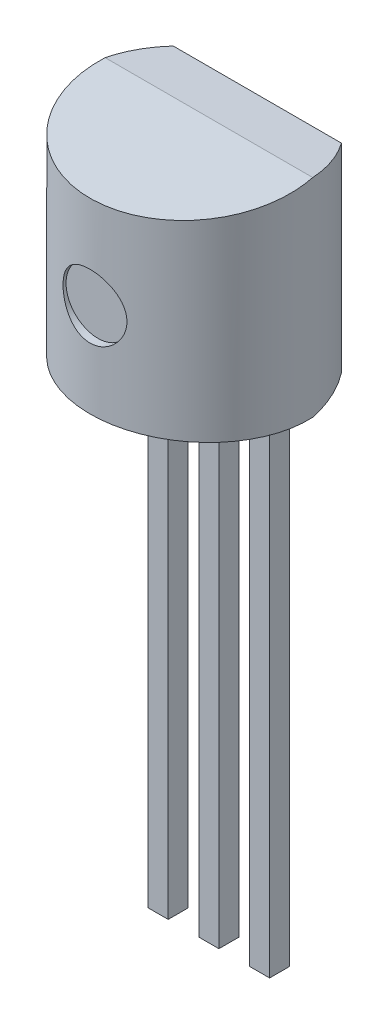
from build123d import *

# Parameters (mm, degrees)
BOSS_EXTRUDE1_DEPTH             = 2.6
SKETCH5_W                       = 11.826356456
SKETCH5_H                       = 5.621169426
CUT_EXTRUDE2_DEPTH              = 7.632050589
SKETCH6_W                       = 11.690711404
SKETCH6_H                       = 7.254613366
CUT_EXTRUDE3_DEPTH              = 5.2
SKETCH7_W                       = 0.5
SKETCH7_H                       = 0.5
BOSS_EXTRUDE2_DEPTH             = 12.7
BOSS_EXTRUDE2_DIRECTION_2_REACH = 8.542
SKETCH8_R                       = 0.8
CUT_EXTRUDE4_DEPTH              = 0.2


with BuildPart() as part:
    # Sketch2 → Boss-Extrude1 (new, symmetric)
    with BuildSketch(Plane(origin=(0, 0, 0), x_dir=(1, 0, 0), z_dir=(0, 1, 0))):
        with BuildLine():
            Line((-2.105447518, 1.212026432), (2.105447518, 1.212026432))
            ThreePointArc((2.105447518, 1.212026432), (0, -2.977973568), (-2.105447518, 1.212026432))
        make_face()
    extrude(amount=BOSS_EXTRUDE1_DEPTH, both=True)

    # Sketch5 → Cut-Extrude2 (cut, through all)
    with BuildSketch(Plane(origin=(0, 2.580250079, -0.225742631), x_dir=(1, 0, 0), z_dir=(0, 0.9961946980917455, -0.08715574274765836))):
        with Locations((0.924694538, -0.744658901)):
            Rectangle(SKETCH5_W, SKETCH5_H)
    cut_extrude2 = extrude(amount=CUT_EXTRUDE2_DEPTH, mode=Mode.SUBTRACT)

    # Sketch6 → Cut-Extrude3 (cut)
    with BuildSketch(Plane(origin=(0, 2.580250079, 0.225742631), x_dir=(1, 0, 0), z_dir=(0, 0.9961946980917467, 0.08715574274764504))):
        with Locations((0.257342704, -2.465539164)):
            Rectangle(SKETCH6_W, SKETCH6_H)
    cut_extrude3 = extrude(amount=CUT_EXTRUDE3_DEPTH, mode=Mode.SUBTRACT)

    # Mirror1: Cut-Extrude2, Cut-Extrude3 across plane
    add(cut_extrude2.mirror(Plane.ZX), mode=Mode.SUBTRACT)
    add(cut_extrude3.mirror(Plane.ZX), mode=Mode.SUBTRACT)


with BuildPart() as boss_extrude2_tool:
    # Sketch7 → Boss-Extrude2 (new body)
    with BuildSketch(Plane(origin=(0, -2.6, 0), x_dir=(-1, 0, 0), z_dir=(0, -1, 0))):
        with Locations((-1.27, 0.25)):
            Rectangle(SKETCH7_W, SKETCH7_H)
        with Locations((0, 0.25)):
            Rectangle(SKETCH7_W, SKETCH7_H)
        with Locations((1.27, 0.25)):
            Rectangle(SKETCH7_W, SKETCH7_H)
    extrude(amount=BOSS_EXTRUDE2_DEPTH)


with BuildPart() as part_1:
    add(part.part)


with BuildPart() as part_2:
    # Boss-Extrude2: joined with boss_extrude2_tool
    add(part_1.part.fuse(boss_extrude2_tool.part, tol=0.00001))

    # Sketch7 → Boss-Extrude2 direction 2 (add, up to next)
    with BuildSketch(Plane(origin=(0, -2.6, 0), x_dir=(-1, 0, 0), z_dir=(0, -1, 0)), mode=Mode.PRIVATE) as boss_extrude2_direction_2_sk1:
        with Locations((-1.27, 0.25)):
            Rectangle(SKETCH7_W, SKETCH7_H)
    boss_extrude2_direction_2_tool1 = extrude(boss_extrude2_direction_2_sk1.sketch, amount=-BOSS_EXTRUDE2_DIRECTION_2_REACH, mode=Mode.PRIVATE) - part_2.part
    # Sketch7 → Boss-Extrude2 direction 2 (add, up to next)
    with BuildSketch(Plane(origin=(0, -2.6, 0), x_dir=(-1, 0, 0), z_dir=(0, -1, 0)), mode=Mode.PRIVATE) as boss_extrude2_direction_2_sk2:
        with Locations((0, 0.25)):
            Rectangle(SKETCH7_W, SKETCH7_H)
    boss_extrude2_direction_2_tool2 = extrude(boss_extrude2_direction_2_sk2.sketch, amount=-BOSS_EXTRUDE2_DIRECTION_2_REACH, mode=Mode.PRIVATE) - part_2.part
    # Sketch7 → Boss-Extrude2 direction 2 (add, up to next)
    with BuildSketch(Plane(origin=(0, -2.6, 0), x_dir=(-1, 0, 0), z_dir=(0, -1, 0)), mode=Mode.PRIVATE) as boss_extrude2_direction_2_sk3:
        with Locations((1.27, 0.25)):
            Rectangle(SKETCH7_W, SKETCH7_H)
    boss_extrude2_direction_2_tool3 = extrude(boss_extrude2_direction_2_sk3.sketch, amount=-BOSS_EXTRUDE2_DIRECTION_2_REACH, mode=Mode.PRIVATE) - part_2.part
    add(boss_extrude2_direction_2_tool1.solids().sort_by_distance((1.27, -2.6, -0.25))[0])
    add(boss_extrude2_direction_2_tool2.solids().sort_by_distance((0, -2.6, -0.25))[0])
    add(boss_extrude2_direction_2_tool3.solids().sort_by_distance((-1.27, -2.6, -0.25))[0])

    # Sketch8 → Cut-Extrude4 (cut)
    with BuildSketch(Plane.XY.offset(2.977973568)):
        Circle(SKETCH8_R)
    extrude(amount=-CUT_EXTRUDE4_DEPTH, mode=Mode.SUBTRACT)


solid = part_2.part
